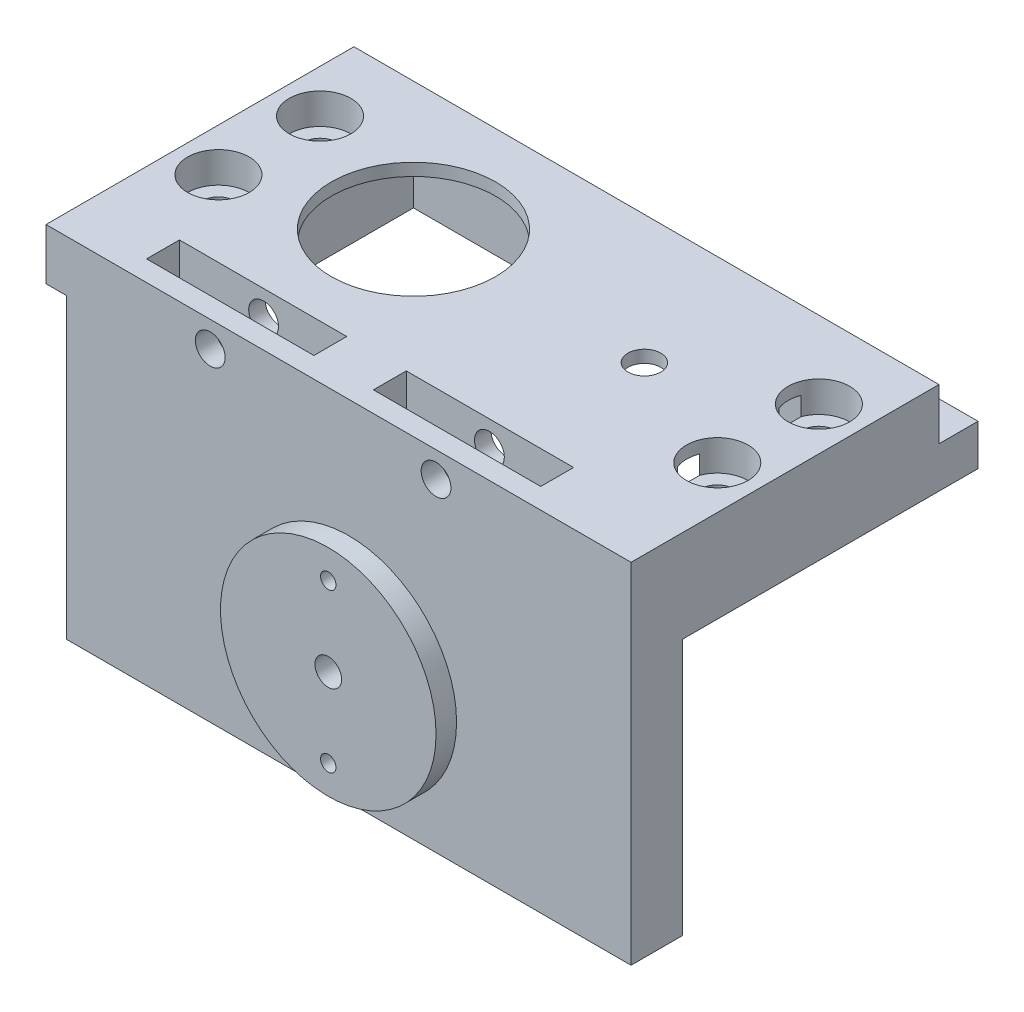
from build123d import *

# Parameters (mm, degrees)
SKETCH1_W                = 50
SKETCH1_H                = 25
SKETCH1_R                = 1.3
SKETCH1_R_2              = 4.5
BOSS_EXTRUDE1_DEPTH      = 2.5
SKETCH2_W                = 50
SKETCH2_H                = 12
BOSS_EXTRUDE2_DEPTH      = 3
SKETCH3_W                = 50
SKETCH3_H                = 28
BOSS_EXTRUDE3_DEPTH      = 3
SKETCH4_R                = 1.3
CUT_EXTRUDE1_DEPTH       = 16
SKETCH5_W                = 53
SKETCH5_H                = 32.5
SKETCH5_R                = 1.6
SKETCH5_W_2              = 42
SKETCH5_H_2              = 21.5
BOSS_EXTRUDE4_DEPTH      = 4
SKETCH7_R                = 8
CUT_EXTRUDE2_DEPTH       = 5
SKETCH8_W                = 24.55
SKETCH8_H                = 21.5
CUT_EXTRUDE3_DEPTH       = 3.8
BOSS_EXTRUDE6_DEPTH      = 22.95
BOSS_EXTRUDE7_DEPTH      = 2
SKETCH11_R               = 1.6
CUT_EXTRUDE4_DEPTH       = 1.2
SKETCH12_W               = 7
SKETCH12_H               = 21
SKETCH12_R               = 1.6
BOSS_EXTRUDE8_DEPTH      = 7.8
SKETCH13_W               = 0.7
SKETCH13_H               = 5
SKETCH13_H_2             = 4
CUT_EXTRUDE5_DEPTH       = 51
CUT_EXTRUDE5_DEPTH_BACK  = 25.95
SKETCH14_W               = 28
SKETCH14_H               = 10
CUT_EXTRUDE6_DEPTH       = 1
CUT_EXTRUDE6_DEPTH_BACK  = 75.95
SKETCH16_R               = 3
CUT_EXTRUDE8_DEPTH       = 3
SKETCH15_R               = 1.6
CUT_EXTRUDE9_DEPTH       = 5
SKETCH17_W               = 16.3
SKETCH17_H               = 5
CUT_EXTRUDE10_DEPTH      = 3.2
SKETCH18_R               = 1.45
CUT_EXTRUDE11_DEPTH      = 5
SKETCH19_R               = 1.6
CUT_EXTRUDE12_DEPTH      = 1.0000001
CUT_EXTRUDE12_DEPTH_BACK = 10
SKETCH20_W               = 17.95
SKETCH20_H               = 5
CUT_EXTRUDE14_DEPTH      = 1
CUT_EXTRUDE14_DEPTH_BACK = 32.8
SKETCH21_W               = 16.3
SKETCH21_H               = 5
SKETCH21_R               = 1.45
BOSS_EXTRUDE11_DEPTH     = 2
SKETCH22_W               = 55
SKETCH22_H               = 5
BOSS_EXTRUDE12_DEPTH     = 25
SKETCH23_R               = 10.5
BOSS_EXTRUDE13_DEPTH     = 2
SKETCH24_R               = 1.3
SKETCH24_R_2             = 0.75
CUT_EXTRUDE16_DEPTH      = 7
SKETCH25_R               = 2.5
SKETCH25_R_2             = 1.3
CUT_EXTRUDE17_DEPTH      = 4


with BuildPart() as part:
    # Sketch1 → Boss-Extrude1 (new body, symmetric)
    with BuildSketch(Plane(origin=(0, 0, 0), x_dir=(1, 0, 0), z_dir=(0, 1, 0))):
        Rectangle(SKETCH1_W, SKETCH1_H)
        with Locations((-11.25, 0)):
            Circle(SKETCH1_R, mode=Mode.SUBTRACT)
        with Locations((11.25, 0)):
            Circle(SKETCH1_R_2, mode=Mode.SUBTRACT)
    extrude(amount=BOSS_EXTRUDE1_DEPTH, both=True)

    # Sketch2 → Boss-Extrude2 (add)
    with BuildSketch(Plane.XY.offset(12.5)):
        with Locations((0, 3.5)):
            Rectangle(SKETCH2_W, SKETCH2_H)
    extrude(amount=BOSS_EXTRUDE2_DEPTH)

    # Sketch3 → Boss-Extrude3 (add)
    with BuildSketch(Plane(origin=(0, 9.5, 0), x_dir=(1, 0, 0), z_dir=(0, 1, 0))):
        with Locations((0, -1.5)):
            Rectangle(SKETCH3_W, SKETCH3_H)
    extrude(amount=BOSS_EXTRUDE3_DEPTH)

    # Sketch4 → Cut-Extrude1 (cut, through all)
    with BuildSketch(Plane(origin=(0, 12.5, 0), x_dir=(1, 0, 0), z_dir=(0, 1, 0))):
        with Locations((11.25, 0)):
            Circle(SKETCH4_R)
        with Locations((-11.25, 0)):
            Circle(SKETCH4_R)
    extrude(amount=-CUT_EXTRUDE1_DEPTH, mode=Mode.SUBTRACT)

    # Sketch5 → Boss-Extrude4 (add)
    with BuildSketch(Plane.XZ.offset(2.5)):
        with Locations((21.45, -0.05)):
            Rectangle(SKETCH5_W, SKETCH5_H)
        with Locations((45.75, -5)):
            Circle(SKETCH5_R, mode=Mode.SUBTRACT)
        with Locations((45.75, 4.9)):
            Circle(SKETCH5_R, mode=Mode.SUBTRACT)
        with Locations((-2.85, 4.9)):
            Circle(SKETCH5_R, mode=Mode.SUBTRACT)
        with Locations((-2.85, -5)):
            Circle(SKETCH5_R, mode=Mode.SUBTRACT)
        with Locations((21.45, -0.05)):
            Rectangle(SKETCH5_W_2, SKETCH5_H_2, mode=Mode.SUBTRACT)
    extrude(amount=BOSS_EXTRUDE4_DEPTH)

    # Sketch7 → Cut-Extrude2 (cut)
    with BuildSketch(Plane.XZ.offset(2.5)):
        with Locations((11.25, 0)):
            Circle(SKETCH7_R)
    extrude(amount=-CUT_EXTRUDE2_DEPTH, mode=Mode.SUBTRACT)

    # Sketch8 → Cut-Extrude3 (cut)
    with BuildSketch(Plane.XZ.offset(2.5)):
        with Locations((12.725, -0.05)):
            Rectangle(SKETCH8_W, SKETCH8_H)
    extrude(amount=-CUT_EXTRUDE3_DEPTH, mode=Mode.SUBTRACT)

    # Sketch9 → Boss-Extrude6 (add)
    with BuildSketch(Plane(origin=(25, 0, 0), x_dir=(0, 0, -1), z_dir=(1, 0, 0))):
        Polygon((12.5, 2.5), (-16.2, 2.5), (-16.2, -2.5), (-10.7, -2.5), (-10.7, 1.3), (10.8, 1.3), (10.8, -2.5), (12.5, -2.5), align=None)
    extrude(amount=BOSS_EXTRUDE6_DEPTH)

    # Sketch10 → Boss-Extrude7 (add)
    with BuildSketch(Plane(origin=(47.95, 0, 0), x_dir=(0, 0, -1), z_dir=(1, 0, 0))):
        Polygon((16.3, -2.5), (12.5, -2.5), (12.5, 2.5), (-16.2, 2.5), (-16.2, -6.5), (16.3, -6.5), align=None)
    extrude(amount=BOSS_EXTRUDE7_DEPTH)

    # Sketch11 → Cut-Extrude4 (cut)
    with BuildSketch(Plane.XZ.offset(-1.3)):
        with Locations((-2.85, 4.9)):
            Circle(SKETCH11_R)
        with Locations((-2.85, -5)):
            Circle(SKETCH11_R)
        with Locations((45.75, 4.9)):
            Circle(SKETCH11_R)
        with Locations((45.75, -5)):
            Circle(SKETCH11_R)
    extrude(amount=-CUT_EXTRUDE4_DEPTH, mode=Mode.SUBTRACT)

    # Sketch12 → Boss-Extrude8 (add)
    with BuildSketch(Plane.XZ.offset(-1.3)):
        with Locations((46.45, 0.2)):
            Rectangle(SKETCH12_W, SKETCH12_H)
        with Locations((45.75, 4.9)):
            Circle(SKETCH12_R, mode=Mode.SUBTRACT)
        with Locations((45.75, -5)):
            Circle(SKETCH12_R, mode=Mode.SUBTRACT)
    extrude(amount=BOSS_EXTRUDE8_DEPTH)

    # Sketch13 → Cut-Extrude5 (cut, two sides)
    with BuildSketch(Plane.ZY.offset(-25)) as cut_extrude5_sk:
        with Locations((15.85, 0)):
            Rectangle(SKETCH13_W, SKETCH13_H)
        with Locations((15.85, -4.5)):
            Rectangle(SKETCH13_W, SKETCH13_H_2)
    extrude(amount=CUT_EXTRUDE5_DEPTH, mode=Mode.SUBTRACT)
    extrude(cut_extrude5_sk.sketch, amount=-CUT_EXTRUDE5_DEPTH_BACK, mode=Mode.SUBTRACT)

    # Sketch14 → Cut-Extrude6 (cut, two sides)
    with BuildSketch(Plane.ZY.offset(25)) as cut_extrude6_sk:
        with Locations((1.5, 7.5)):
            Rectangle(SKETCH14_W, SKETCH14_H)
    extrude(amount=CUT_EXTRUDE6_DEPTH, mode=Mode.SUBTRACT)
    extrude(cut_extrude6_sk.sketch, amount=-CUT_EXTRUDE6_DEPTH_BACK, mode=Mode.SUBTRACT)

    # Sketch16 → Cut-Extrude8 (cut)
    with BuildSketch(Plane(origin=(0, 2.5, 0), x_dir=(1, 0, 0), z_dir=(0, 1, 0))):
        with Locations((-2.85, 5)):
            Circle(SKETCH16_R)
        with Locations((-2.85, -4.9)):
            Circle(SKETCH16_R)
        with Locations((45.75, 5)):
            Circle(SKETCH16_R)
        with Locations((45.75, -4.9)):
            Circle(SKETCH16_R)
    extrude(amount=-CUT_EXTRUDE8_DEPTH, mode=Mode.SUBTRACT)

    # Sketch15 → Cut-Extrude9 (cut)
    with BuildSketch(Plane(origin=(0, 2.5, 0), x_dir=(1, 0, 0), z_dir=(0, 1, 0))):
        with Locations((-2.85, 5)):
            Circle(SKETCH15_R)
        with Locations((-2.85, -4.9)):
            Circle(SKETCH15_R)
    extrude(amount=-CUT_EXTRUDE9_DEPTH, mode=Mode.SUBTRACT)

    # Sketch17 → Cut-Extrude10 (cut)
    with BuildSketch(Plane.XY.offset(15.5)):
        with Locations((8.9, 0)):
            Rectangle(SKETCH17_W, SKETCH17_H)
        with Locations((31, 0)):
            Rectangle(SKETCH17_W, SKETCH17_H)
    extrude(amount=-CUT_EXTRUDE10_DEPTH, mode=Mode.SUBTRACT)

    # Sketch18 → Cut-Extrude11 (cut)
    with BuildSketch(Plane.XY.offset(12.3)):
        with Locations((8.95, 0)):
            Circle(SKETCH18_R)
        with Locations((30.95, 0)):
            Circle(SKETCH18_R)
    extrude(amount=-CUT_EXTRUDE11_DEPTH, mode=Mode.SUBTRACT)

    # Sketch19 → Cut-Extrude12 (cut, two sides)
    with BuildSketch(Plane(origin=(0, 2.5, 0), x_dir=(1, 0, 0), z_dir=(0, 1, 0))) as cut_extrude12_sk:
        with Locations((33.75, 0)):
            Circle(SKETCH19_R)
    extrude(amount=CUT_EXTRUDE12_DEPTH, mode=Mode.SUBTRACT)
    extrude(cut_extrude12_sk.sketch, amount=-CUT_EXTRUDE12_DEPTH_BACK, mode=Mode.SUBTRACT)

    # Sketch20 → Cut-Extrude14 (cut, two sides)
    with BuildSketch(Plane.XY.offset(15.5)) as cut_extrude14_sk:
        with Locations((-16.025, 0)):
            Rectangle(SKETCH20_W, SKETCH20_H)
    extrude(amount=CUT_EXTRUDE14_DEPTH, mode=Mode.SUBTRACT)
    extrude(cut_extrude14_sk.sketch, amount=-CUT_EXTRUDE14_DEPTH_BACK, mode=Mode.SUBTRACT)

    # Sketch21 → Boss-Extrude11 (add)
    with BuildSketch(Plane.XY.offset(15.5)):
        with Locations((8.9, 0)):
            Rectangle(SKETCH21_W, SKETCH21_H)
        with Locations((8.95, 0)):
            Circle(SKETCH21_R, mode=Mode.SUBTRACT)
        Polygon((0.75, -2.5), (0.75, 2.5), (-7.05, 2.5), (-7.05, -2.5), (-5.05, -2.5), (-5.05, -6.5), (49.95, -6.5), (49.95, 2.5), (39.15, 2.5), (39.15, -2.5), (22.85, -2.5), (22.85, 2.5), (17.05, 2.5), (17.05, -2.5), align=None)
        with Locations((31, 0)):
            Rectangle(SKETCH21_W, SKETCH21_H)
        with Locations((30.95, 0)):
            Circle(SKETCH21_R, mode=Mode.SUBTRACT)
    extrude(amount=BOSS_EXTRUDE11_DEPTH)

    # Sketch22 → Boss-Extrude12 (add)
    with BuildSketch(Plane.XZ.offset(6.5)):
        with Locations((22.45, 15)):
            Rectangle(SKETCH22_W, SKETCH22_H)
    extrude(amount=BOSS_EXTRUDE12_DEPTH)

    # Sketch23 → Boss-Extrude13 (add)
    with BuildSketch(Plane.XY.offset(17.5)):
        with Locations((22.45, -19.5)):
            Circle(SKETCH23_R)
    extrude(amount=BOSS_EXTRUDE13_DEPTH)

    # Sketch24 → Cut-Extrude16 (cut)
    with BuildSketch(Plane.XY.offset(19.5)):
        with Locations((22.45, -19.5)):
            Circle(SKETCH24_R)
        with Locations((22.45, -11.8)):
            Circle(SKETCH24_R_2)
        with Locations((22.45, -27.2)):
            Circle(SKETCH24_R_2)
    extrude(amount=-CUT_EXTRUDE16_DEPTH, mode=Mode.SUBTRACT)

    # Sketch25 → Cut-Extrude17 (cut)
    with BuildSketch(Plane(origin=(0, 0, 12.5), x_dir=(-1, 0, 0), z_dir=(0, 0, -1))):
        with Locations((-22.45, -19.5)):
            Circle(SKETCH25_R)
        with Locations((-22.45, -19.5)):
            Circle(SKETCH25_R_2, mode=Mode.SUBTRACT)
    extrude(amount=-CUT_EXTRUDE17_DEPTH, mode=Mode.SUBTRACT)


solid = part.part
